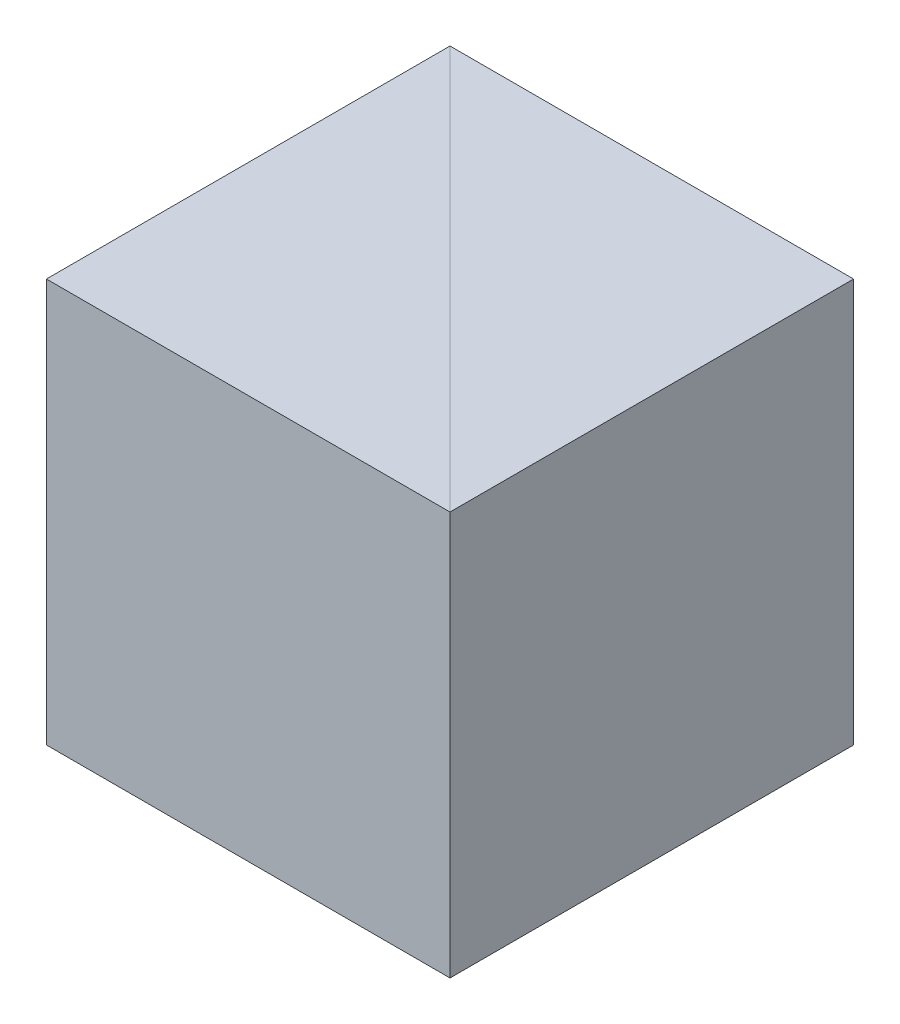
from build123d import *

# Parameters (mm, degrees)
EXTRUDE_1_DEPTH = 25
EXTRUDE_2_DEPTH = 25


with BuildPart() as part:
    # 草图1 → 凸台-拉伸1 (new body)
    with BuildSketch(Plane(origin=(0, 0, 0), x_dir=(1, 0, 0), z_dir=(0, 1, 0))):
        Polygon((0, 0), (0, 25), (-25, 25), align=None)
    extrude(amount=EXTRUDE_1_DEPTH)


with BuildPart() as body_2:
    # 草图2 → 凸台-拉伸2 (new body)
    with BuildSketch(Plane.XZ):
        Polygon((-25, -25), (-25, 0), (0, 0), align=None)
    extrude(amount=-EXTRUDE_2_DEPTH)


solid = Compound([part.part, body_2.part])
